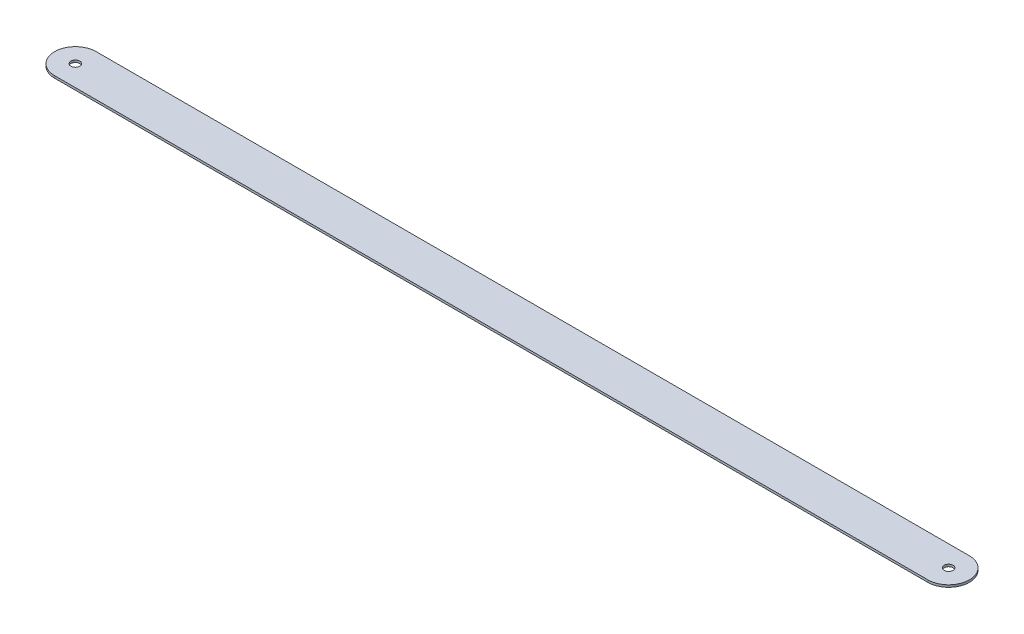
from build123d import *

# Parameters (mm, degrees)
SKETCH1_R           = 3
BOSS_EXTRUDE1_DEPTH = 1.5


with BuildPart() as part:
    # Sketch1 → Boss-Extrude1 (new body)
    with BuildSketch(Plane(origin=(0, 0, 0), x_dir=(1, 0, 0), z_dir=(0, 1, 0))):
        with BuildLine():
            Line((0, 14), (587.63, 14))
            ThreePointArc((587.63, 14), (601.63, 0), (587.63, -14))
            Line((587.63, -14), (0, -14))
            ThreePointArc((0, -14), (-14, 0), (0, 14))
        make_face()
        Circle(SKETCH1_R, mode=Mode.SUBTRACT)
        with Locations((587.63, 0)):
            Circle(SKETCH1_R, mode=Mode.SUBTRACT)
    extrude(amount=BOSS_EXTRUDE1_DEPTH)


solid = part.part
